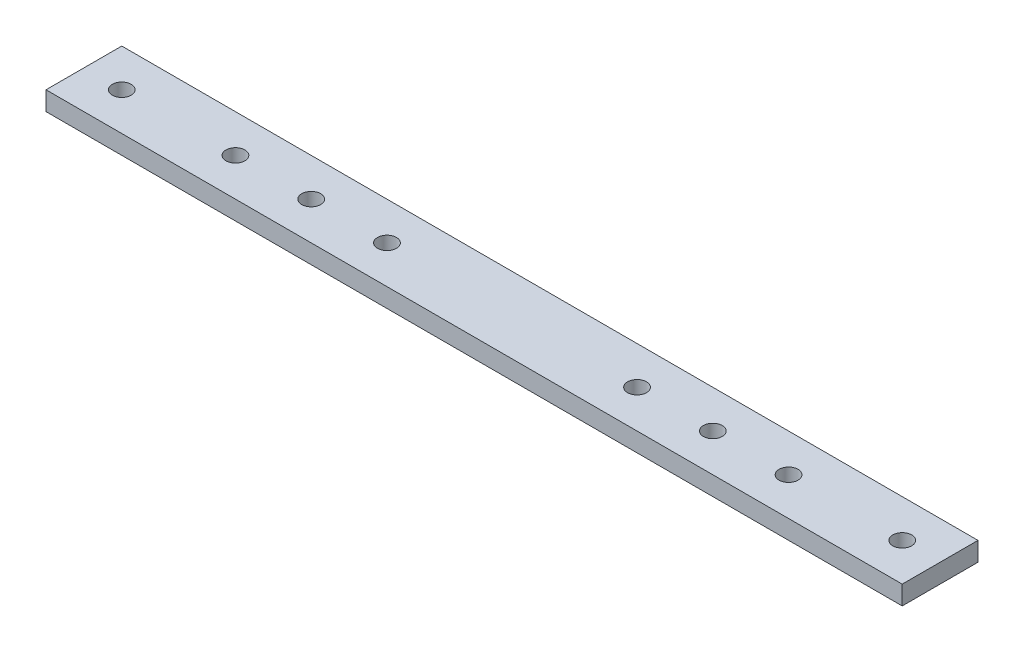
from build123d import *

# Parameters (mm, degrees)
SKETCH1_W               = 287.02
SKETCH1_H               = 25.4
BOSS_EXTRUDE1_DEPTH     = 3.175
SKETCH2_R               = 3.175
CUT_EXTRUDE1_DEPTH      = 1
CUT_EXTRUDE1_DEPTH_BACK = 7.35


with BuildPart() as part:
    # Sketch1 → Boss-Extrude1 (new body, symmetric)
    with BuildSketch(Plane(origin=(0, 0, 0), x_dir=(1, 0, 0), z_dir=(0, 1, 0))):
        Rectangle(SKETCH1_W, SKETCH1_H)
    extrude(amount=BOSS_EXTRUDE1_DEPTH, both=True)

    # Sketch2 → Cut-Extrude1 (cut, two sides)
    with BuildSketch(Plane(origin=(0, 3.175, 0), x_dir=(1, 0, 0), z_dir=(0, 1, 0))) as cut_extrude1_sk:
        with Locations((-130.81, 0)):
            Circle(SKETCH2_R)
        with Locations((-41.91, 0)):
            Circle(SKETCH2_R)
        with Locations((130.81, 0)):
            Circle(SKETCH2_R)
        with Locations((41.91, 0)):
            Circle(SKETCH2_R)
        with Locations((-92.71, 0)):
            Circle(SKETCH2_R)
        with Locations((-67.31, 0)):
            Circle(SKETCH2_R)
        with Locations((67.31, 0)):
            Circle(SKETCH2_R)
        with Locations((92.71, 0)):
            Circle(SKETCH2_R)
    extrude(amount=CUT_EXTRUDE1_DEPTH, mode=Mode.SUBTRACT)
    extrude(cut_extrude1_sk.sketch, amount=-CUT_EXTRUDE1_DEPTH_BACK, mode=Mode.SUBTRACT)


solid = part.part
